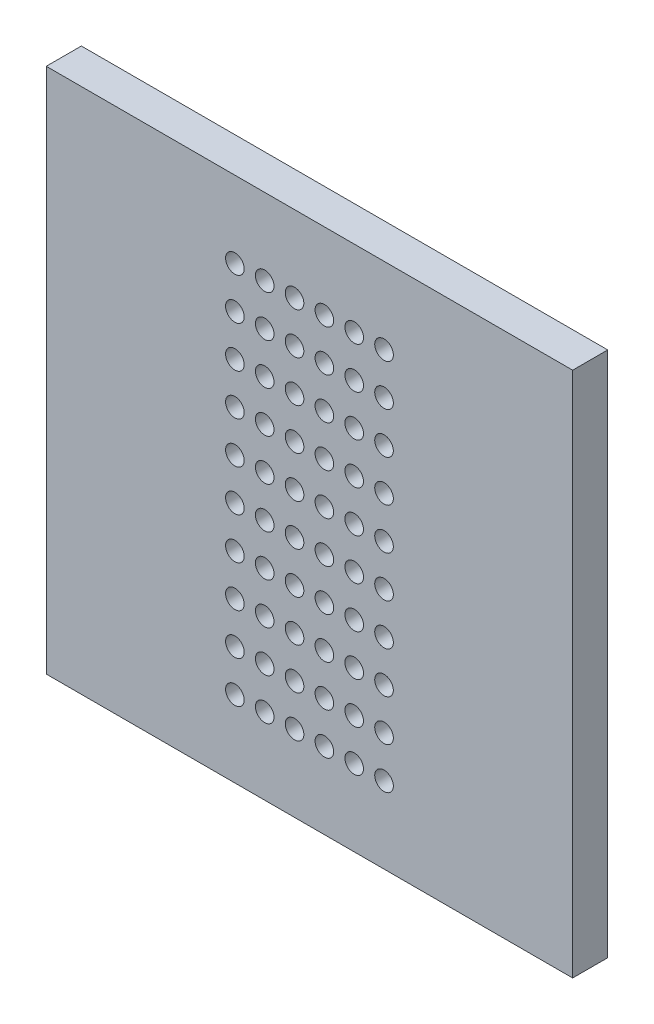
from build123d import *

# Parameters (mm, degrees)
ESQUISSE1_W            = 30
ESQUISSE1_H            = 30
BASE_PLATE_DEPTH       = 2
SKETCH_PERFORATIONS_R  = 0.53
CUT_PERFORATIONS_DEPTH = 10


with BuildPart() as part:
    # Esquisse1 → Base_Plate (new body)
    with BuildSketch(Plane.XY):
        Rectangle(ESQUISSE1_W, ESQUISSE1_H)
    extrude(amount=BASE_PLATE_DEPTH)

    # Sketch_Perforations → Cut_Perforations (cut)
    with BuildSketch(Plane.XY.offset(2)):
        with Locations((-4.25, -10.64)):
            Circle(SKETCH_PERFORATIONS_R)
        with Locations((-4.25, -8.27)):
            Circle(SKETCH_PERFORATIONS_R)
        with Locations((-4.25, -5.91)):
            Circle(SKETCH_PERFORATIONS_R)
        with Locations((-4.25, -3.55)):
            Circle(SKETCH_PERFORATIONS_R)
        with Locations((-4.25, -1.18)):
            Circle(SKETCH_PERFORATIONS_R)
        with Locations((-4.25, 1.18)):
            Circle(SKETCH_PERFORATIONS_R)
        with Locations((-4.25, 3.55)):
            Circle(SKETCH_PERFORATIONS_R)
        with Locations((-4.25, 5.91)):
            Circle(SKETCH_PERFORATIONS_R)
        with Locations((-4.25, 8.27)):
            Circle(SKETCH_PERFORATIONS_R)
        with Locations((-4.25, 10.64)):
            Circle(SKETCH_PERFORATIONS_R)
        with Locations((-2.55, -10.64)):
            Circle(SKETCH_PERFORATIONS_R)
        with Locations((-2.55, -8.27)):
            Circle(SKETCH_PERFORATIONS_R)
        with Locations((-2.55, -5.91)):
            Circle(SKETCH_PERFORATIONS_R)
        with Locations((-2.55, -3.55)):
            Circle(SKETCH_PERFORATIONS_R)
        with Locations((-2.55, -1.18)):
            Circle(SKETCH_PERFORATIONS_R)
        with Locations((-2.55, 1.18)):
            Circle(SKETCH_PERFORATIONS_R)
        with Locations((-2.55, 3.55)):
            Circle(SKETCH_PERFORATIONS_R)
        with Locations((-2.55, 5.91)):
            Circle(SKETCH_PERFORATIONS_R)
        with Locations((-2.55, 8.27)):
            Circle(SKETCH_PERFORATIONS_R)
        with Locations((-2.55, 10.64)):
            Circle(SKETCH_PERFORATIONS_R)
        with Locations((-0.85, -10.64)):
            Circle(SKETCH_PERFORATIONS_R)
        with Locations((-0.85, -8.27)):
            Circle(SKETCH_PERFORATIONS_R)
        with Locations((-0.85, -5.91)):
            Circle(SKETCH_PERFORATIONS_R)
        with Locations((-0.85, -3.55)):
            Circle(SKETCH_PERFORATIONS_R)
        with Locations((-0.85, -1.18)):
            Circle(SKETCH_PERFORATIONS_R)
        with Locations((-0.85, 1.18)):
            Circle(SKETCH_PERFORATIONS_R)
        with Locations((-0.85, 3.55)):
            Circle(SKETCH_PERFORATIONS_R)
        with Locations((-0.85, 5.91)):
            Circle(SKETCH_PERFORATIONS_R)
        with Locations((-0.85, 8.27)):
            Circle(SKETCH_PERFORATIONS_R)
        with Locations((-0.85, 10.64)):
            Circle(SKETCH_PERFORATIONS_R)
        with Locations((0.85, -10.64)):
            Circle(SKETCH_PERFORATIONS_R)
        with Locations((0.85, -8.27)):
            Circle(SKETCH_PERFORATIONS_R)
        with Locations((0.85, -5.91)):
            Circle(SKETCH_PERFORATIONS_R)
        with Locations((0.85, -3.55)):
            Circle(SKETCH_PERFORATIONS_R)
        with Locations((0.85, -1.18)):
            Circle(SKETCH_PERFORATIONS_R)
        with Locations((0.85, 1.18)):
            Circle(SKETCH_PERFORATIONS_R)
        with Locations((0.85, 3.55)):
            Circle(SKETCH_PERFORATIONS_R)
        with Locations((0.85, 5.91)):
            Circle(SKETCH_PERFORATIONS_R)
        with Locations((0.85, 8.27)):
            Circle(SKETCH_PERFORATIONS_R)
        with Locations((0.85, 10.64)):
            Circle(SKETCH_PERFORATIONS_R)
        with Locations((2.55, -10.64)):
            Circle(SKETCH_PERFORATIONS_R)
        with Locations((2.55, -8.27)):
            Circle(SKETCH_PERFORATIONS_R)
        with Locations((2.55, -5.91)):
            Circle(SKETCH_PERFORATIONS_R)
        with Locations((2.55, -3.55)):
            Circle(SKETCH_PERFORATIONS_R)
        with Locations((2.55, -1.18)):
            Circle(SKETCH_PERFORATIONS_R)
        with Locations((2.55, 1.18)):
            Circle(SKETCH_PERFORATIONS_R)
        with Locations((2.55, 3.55)):
            Circle(SKETCH_PERFORATIONS_R)
        with Locations((2.55, 5.91)):
            Circle(SKETCH_PERFORATIONS_R)
        with Locations((2.55, 8.27)):
            Circle(SKETCH_PERFORATIONS_R)
        with Locations((2.55, 10.64)):
            Circle(SKETCH_PERFORATIONS_R)
        with Locations((4.25, -10.64)):
            Circle(SKETCH_PERFORATIONS_R)
        with Locations((4.25, -8.27)):
            Circle(SKETCH_PERFORATIONS_R)
        with Locations((4.25, -5.91)):
            Circle(SKETCH_PERFORATIONS_R)
        with Locations((4.25, -3.55)):
            Circle(SKETCH_PERFORATIONS_R)
        with Locations((4.25, -1.18)):
            Circle(SKETCH_PERFORATIONS_R)
        with Locations((4.25, 1.18)):
            Circle(SKETCH_PERFORATIONS_R)
        with Locations((4.25, 3.55)):
            Circle(SKETCH_PERFORATIONS_R)
        with Locations((4.25, 5.91)):
            Circle(SKETCH_PERFORATIONS_R)
        with Locations((4.25, 8.27)):
            Circle(SKETCH_PERFORATIONS_R)
        with Locations((4.25, 10.64)):
            Circle(SKETCH_PERFORATIONS_R)
    extrude(amount=-CUT_PERFORATIONS_DEPTH, mode=Mode.SUBTRACT)


solid = part.part
